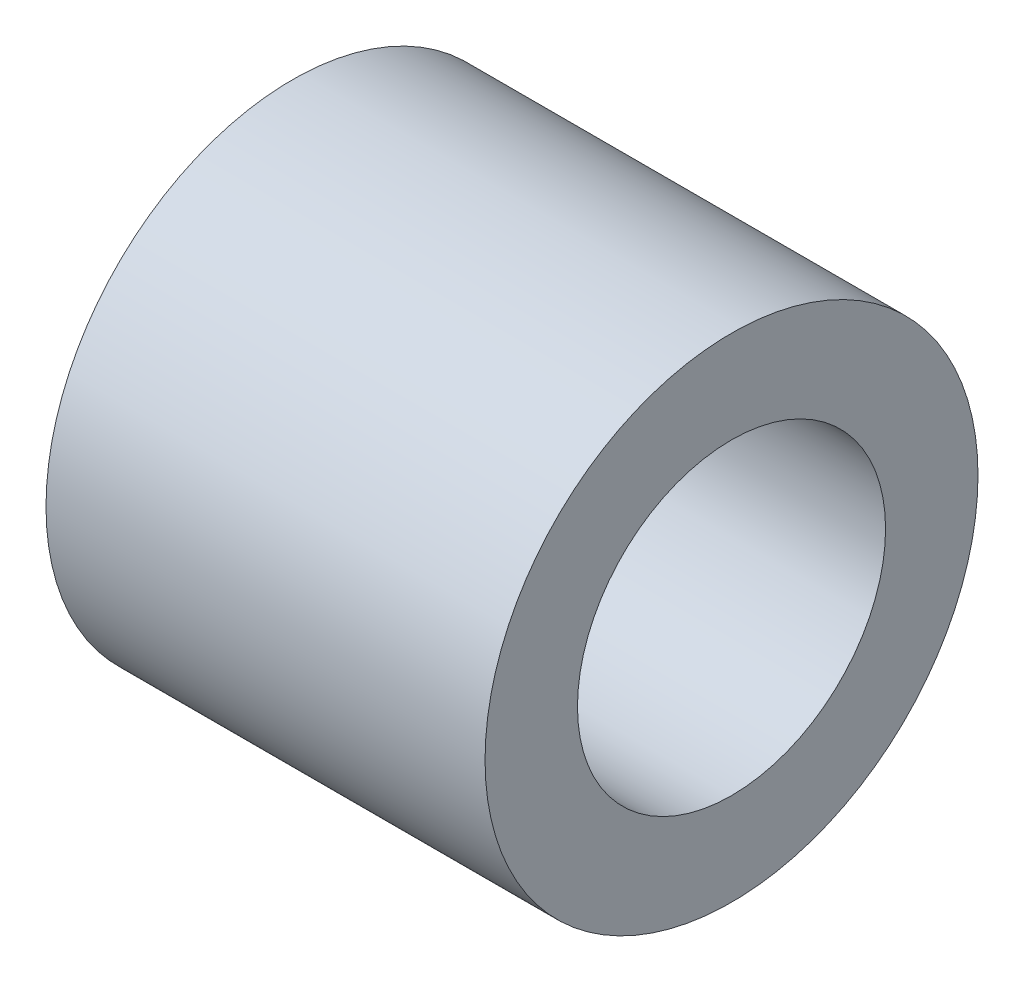
from build123d import *

# Parameters (mm, degrees)
ESQUISSE1_W = 2.85
ESQUISSE1_H = 0.6


with BuildPart() as part:
    # Esquisse1 → Révolution1 (revolve)
    with BuildSketch(Plane.XY):
        with Locations((2.425, 1.3)):
            Rectangle(ESQUISSE1_W, ESQUISSE1_H)
    revolve(axis=Axis((0, 0, 0), (1, 0, 0)))


solid = part.part
